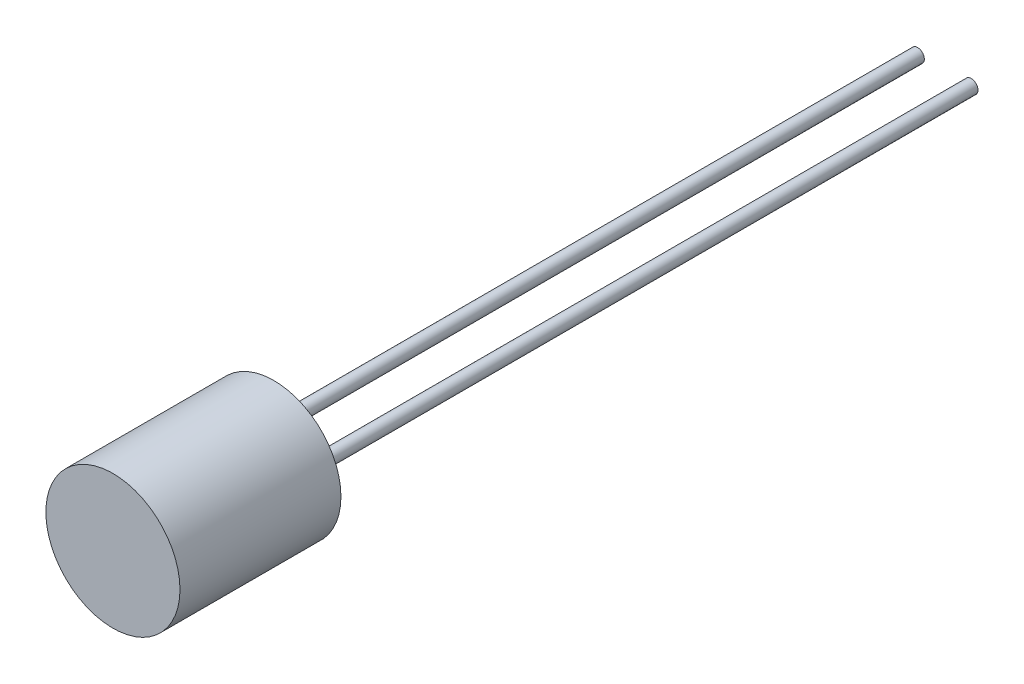
from build123d import *

# Parameters (mm, degrees)
SKETCH1_R           = 2.5
BOSS_EXTRUDE1_DEPTH = 6
SKETCH2_R           = 0.25
BOSS_EXTRUDE2_DEPTH = 25


with BuildPart() as part:
    # Sketch1 → Boss-Extrude1 (new body)
    with BuildSketch(Plane.XY):
        Circle(SKETCH1_R)
    extrude(amount=BOSS_EXTRUDE1_DEPTH)

    # Sketch2 → Boss-Extrude2 (add)
    with BuildSketch(Plane.XY):
        with Locations((-1, 0)):
            Circle(SKETCH2_R)
        with Locations((1, 0)):
            Circle(SKETCH2_R)
    extrude(amount=-BOSS_EXTRUDE2_DEPTH)


solid = part.part
